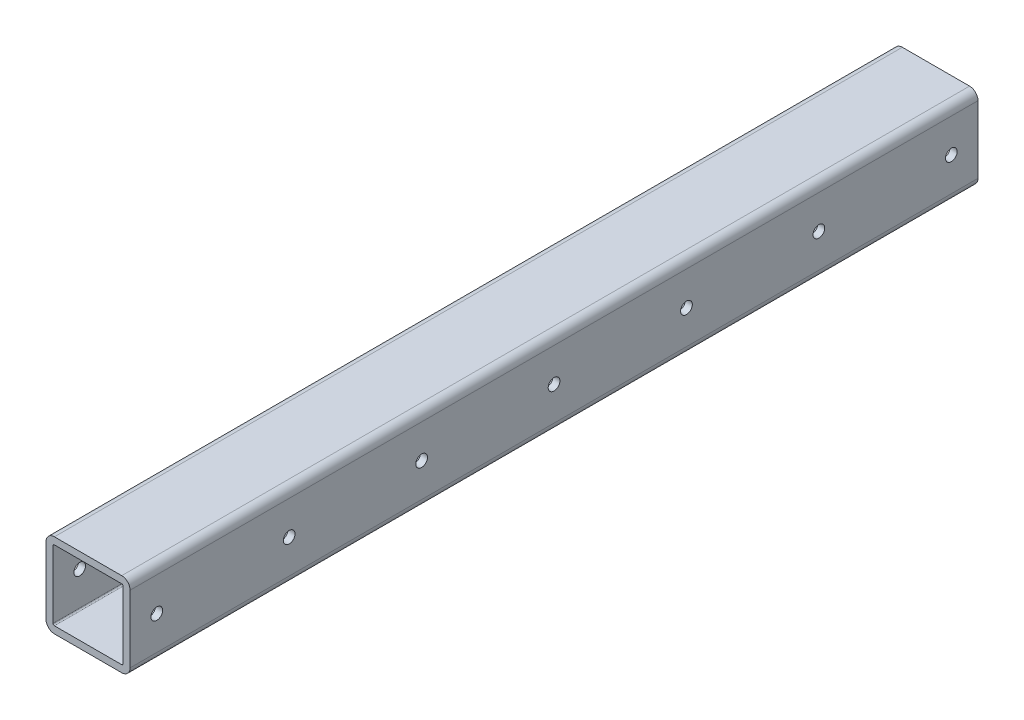
from build123d import *

# Parameters (mm, degrees)
SKETCH1_W               = 38.1
SKETCH1_H               = 38.1
SKETCH1_W_2             = 31.75
SKETCH1_H_2             = 31.75
BOSS_EXTRUDE1_DEPTH     = 192.0875
FILLET1_R               = 3.81
FILLET2_R               = 0.635
SKETCH2_R               = 2.65
CUT_EXTRUDE1_DEPTH      = 20.05
CUT_EXTRUDE1_DEPTH_BACK = 20.05


with BuildPart() as part:
    # Sketch1 → Boss-Extrude1 (new body, symmetric)
    with BuildSketch(Plane.XY):
        Rectangle(SKETCH1_W, SKETCH1_H)
        Rectangle(SKETCH1_W_2, SKETCH1_H_2, mode=Mode.SUBTRACT)
    extrude(amount=BOSS_EXTRUDE1_DEPTH, both=True)

    # Fillet1
    fillet1_edges = [part.edges().sort_by_distance(p)[0] for p in [
        (19.05, -19.05, 0),
        (-19.05, -19.05, 0),
        (-19.05, 19.05, 0),
        (19.05, 19.05, 0),
    ]]
    fillet(fillet1_edges, radius=FILLET1_R)

    # Fillet2
    fillet2_edges = [part.edges().sort_by_distance(p)[0] for p in [
        (15.875, -15.875, 0),
        (15.875, 15.875, 0),
        (-15.875, 15.875, 0),
        (-15.875, -15.875, 0),
    ]]
    fillet(fillet2_edges, radius=FILLET2_R)

    # Sketch2 → Cut-Extrude1 (cut, two sides)
    with BuildSketch(Plane(origin=(0, 0, 0), x_dir=(0, 0, -1), z_dir=(1, 0, 0))) as cut_extrude1_sk:
        with Locations((-180, 0)):
            Circle(SKETCH2_R)
        with Locations((-120, 0)):
            Circle(SKETCH2_R)
        with Locations((-60, 0)):
            Circle(SKETCH2_R)
        Circle(SKETCH2_R)
        with Locations((60, 0)):
            Circle(SKETCH2_R)
        with Locations((120, 0)):
            Circle(SKETCH2_R)
        with Locations((180, 0)):
            Circle(SKETCH2_R)
    extrude(amount=CUT_EXTRUDE1_DEPTH, mode=Mode.SUBTRACT)
    extrude(cut_extrude1_sk.sketch, amount=-CUT_EXTRUDE1_DEPTH_BACK, mode=Mode.SUBTRACT)


solid = part.part
